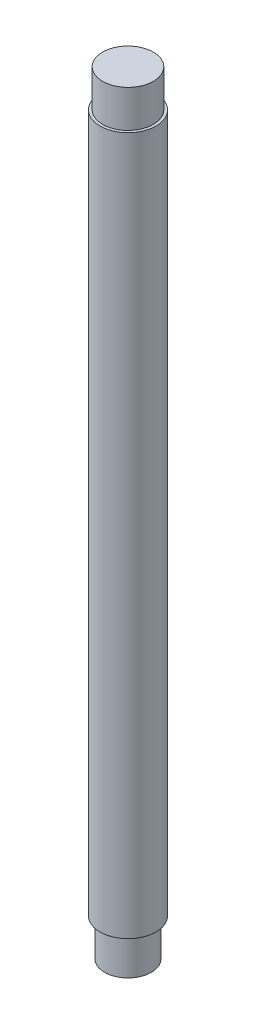
from build123d import *

# Parameters (mm, degrees)
SKETCH2_R           = 9.525
BOSS_EXTRUDE1_DEPTH = 237.399999964
SKETCH3_R           = 8.621005773
BOSS_EXTRUDE2_DEPTH = 12.7
SKETCH4_R           = 7.9375
BOSS_EXTRUDE3_DEPTH = 12.7


with BuildPart() as part:
    # Sketch2 → Boss-Extrude1 (new body)
    with BuildSketch(Plane(origin=(0, 0, 0), x_dir=(1, 0, 0), z_dir=(0, 1, 0))):
        Circle(SKETCH2_R)
    extrude(amount=BOSS_EXTRUDE1_DEPTH)

    # Sketch3 → Boss-Extrude2 (add)
    with BuildSketch(Plane(origin=(0, 237.399999964, 0), x_dir=(1, 0, 0), z_dir=(0, 1, 0))):
        Circle(SKETCH3_R)
    extrude(amount=BOSS_EXTRUDE2_DEPTH)

    # Sketch4 → Boss-Extrude3 (add)
    with BuildSketch(Plane.XZ):
        Circle(SKETCH4_R)
    extrude(amount=BOSS_EXTRUDE3_DEPTH)


solid = part.part
